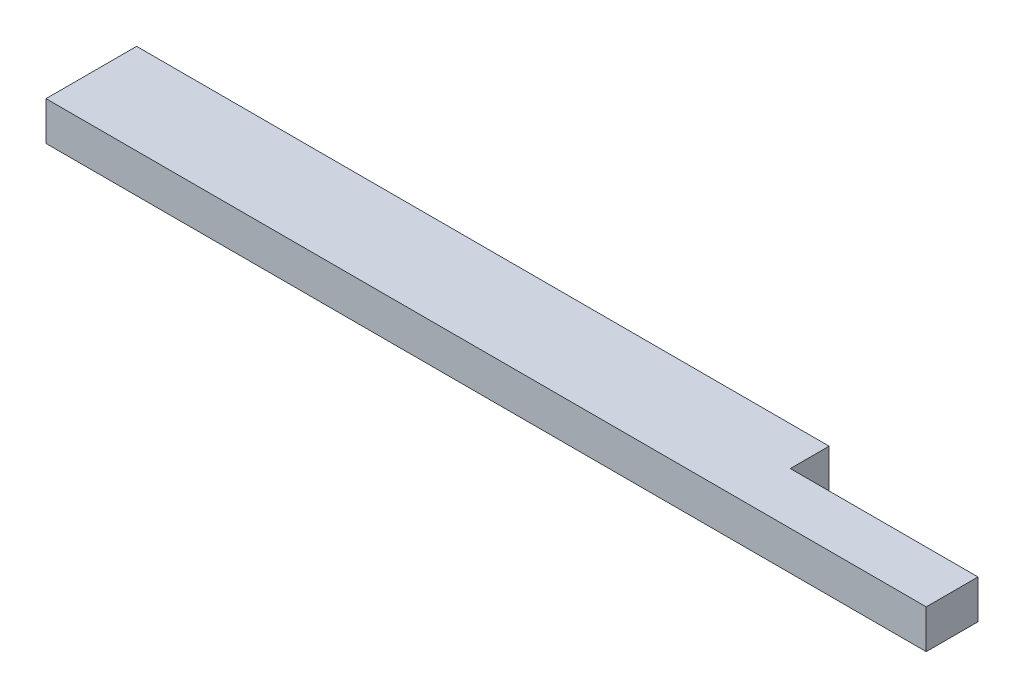
from build123d import *

# Parameters (mm, degrees)
SKETCH1_W           = 863.6
SKETCH1_H           = 88.9
BOSS_EXTRUDE1_DEPTH = 38.1
SKETCH3_W           = 184.15
SKETCH3_H           = 38.1
CUT_EXTRUDE1_DEPTH  = 39.1


with BuildPart() as part:
    # Sketch1 → Boss-Extrude1 (new body)
    with BuildSketch(Plane(origin=(0, 0, 0), x_dir=(1, 0, 0), z_dir=(0, 1, 0))):
        with Locations((431.8, 44.45)):
            Rectangle(SKETCH1_W, SKETCH1_H)
    extrude(amount=BOSS_EXTRUDE1_DEPTH)

    # Sketch3 → Cut-Extrude1 (cut, through all)
    with BuildSketch(Plane(origin=(0, 38.1, 0), x_dir=(1, 0, 0), z_dir=(0, 1, 0))):
        with Locations((771.525, 69.85)):
            Rectangle(SKETCH3_W, SKETCH3_H)
    extrude(amount=-CUT_EXTRUDE1_DEPTH, mode=Mode.SUBTRACT)


solid = part.part
